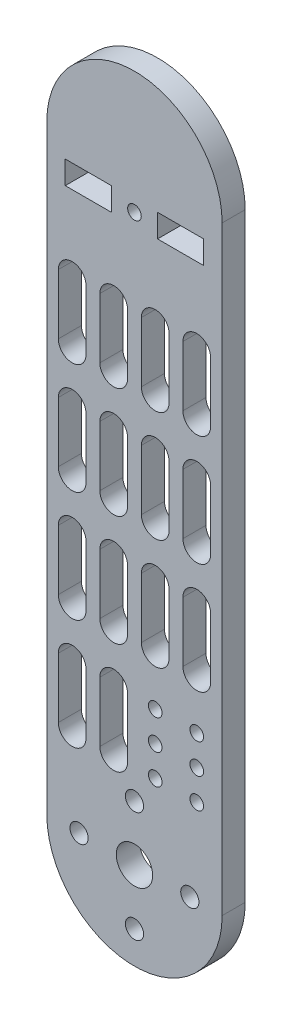
from build123d import *

# Parameters (mm, degrees)
SKETCH1_R           = 3.95
SKETCH1_R_2         = 1.975
SKETCH1_R_3         = 1.475
SKETCH1_W           = 10
SKETCH1_H           = 5
BOSS_EXTRUDE1_DEPTH = 5


with BuildPart() as part:
    # Sketch1 → Boss-Extrude1 (new body)
    with BuildSketch(Plane.XY):
        with BuildLine():
            Line((-19, 0), (-19, 130))
            ThreePointArc((-19, 130), (0, 149), (19, 130))
            Line((19, 130), (19, 0))
            ThreePointArc((19, 0), (0, -19), (-19, 0))
        make_face()
        Circle(SKETCH1_R, mode=Mode.SUBTRACT)
        with Locations((0, 12)):
            Circle(SKETCH1_R_2, mode=Mode.SUBTRACT)
        with Locations((12, 0)):
            Circle(SKETCH1_R_2, mode=Mode.SUBTRACT)
        with Locations((0, -12)):
            Circle(SKETCH1_R_2, mode=Mode.SUBTRACT)
        with Locations((-12, 0)):
            Circle(SKETCH1_R_2, mode=Mode.SUBTRACT)
        with Locations((13.5, 25)):
            Circle(SKETCH1_R_3, mode=Mode.SUBTRACT)
        with Locations((4.5, 25)):
            Circle(SKETCH1_R_3, mode=Mode.SUBTRACT)
        with Locations((13.5, 31.5)):
            Circle(SKETCH1_R_3, mode=Mode.SUBTRACT)
        with Locations((4.5, 31.5)):
            Circle(SKETCH1_R_3, mode=Mode.SUBTRACT)
        with Locations((13.5, 18.5)):
            Circle(SKETCH1_R_3, mode=Mode.SUBTRACT)
        with Locations((4.5, 18.5)):
            Circle(SKETCH1_R_3, mode=Mode.SUBTRACT)
        with Locations((0, 122.5)):
            Circle(SKETCH1_R_3, mode=Mode.SUBTRACT)
        with BuildLine():
            Line((7.5, 103.5), (7.5, 90.5))
            ThreePointArc((7.5, 90.5), (4.5, 87.5), (1.5, 90.5))
            Line((1.5, 90.5), (1.5, 103.5))
            ThreePointArc((1.5, 103.5), (4.5, 106.5), (7.5, 103.5))
        make_face(mode=Mode.SUBTRACT)
        with BuildLine():
            Line((-7.5, 103.5), (-7.5, 90.5))
            ThreePointArc((-7.5, 90.5), (-4.5, 87.5), (-1.5, 90.5))
            Line((-1.5, 90.5), (-1.5, 103.5))
            ThreePointArc((-1.5, 103.5), (-4.5, 106.5), (-7.5, 103.5))
        make_face(mode=Mode.SUBTRACT)
        with BuildLine():
            Line((16.5, 103.5), (16.5, 90.5))
            ThreePointArc((16.5, 90.5), (13.5, 87.5), (10.5, 90.5))
            Line((10.5, 90.5), (10.5, 103.5))
            ThreePointArc((10.5, 103.5), (13.5, 106.5), (16.5, 103.5))
        make_face(mode=Mode.SUBTRACT)
        with BuildLine():
            Line((-16.5, 103.5), (-16.5, 90.5))
            ThreePointArc((-16.5, 90.5), (-13.5, 87.5), (-10.5, 90.5))
            Line((-10.5, 90.5), (-10.5, 103.5))
            ThreePointArc((-10.5, 103.5), (-13.5, 106.5), (-16.5, 103.5))
        make_face(mode=Mode.SUBTRACT)
        with BuildLine():
            Line((7.5, 79.5), (7.5, 66.5))
            ThreePointArc((7.5, 66.5), (4.5, 63.5), (1.5, 66.5))
            Line((1.5, 66.5), (1.5, 79.5))
            ThreePointArc((1.5, 79.5), (4.5, 82.5), (7.5, 79.5))
        make_face(mode=Mode.SUBTRACT)
        with BuildLine():
            Line((-7.5, 79.5), (-7.5, 66.5))
            ThreePointArc((-7.5, 66.5), (-4.5, 63.5), (-1.5, 66.5))
            Line((-1.5, 66.5), (-1.5, 79.5))
            ThreePointArc((-1.5, 79.5), (-4.5, 82.5), (-7.5, 79.5))
        make_face(mode=Mode.SUBTRACT)
        with BuildLine():
            Line((16.5, 79.5), (16.5, 66.5))
            ThreePointArc((16.5, 66.5), (13.5, 63.5), (10.5, 66.5))
            Line((10.5, 66.5), (10.5, 79.5))
            ThreePointArc((10.5, 79.5), (13.5, 82.5), (16.5, 79.5))
        make_face(mode=Mode.SUBTRACT)
        with BuildLine():
            Line((-16.5, 79.5), (-16.5, 66.5))
            ThreePointArc((-16.5, 66.5), (-13.5, 63.5), (-10.5, 66.5))
            Line((-10.5, 66.5), (-10.5, 79.5))
            ThreePointArc((-10.5, 79.5), (-13.5, 82.5), (-16.5, 79.5))
        make_face(mode=Mode.SUBTRACT)
        with BuildLine():
            Line((7.5, 55.5), (7.5, 42.5))
            ThreePointArc((7.5, 42.5), (4.5, 39.5), (1.5, 42.5))
            Line((1.5, 42.5), (1.5, 55.5))
            ThreePointArc((1.5, 55.5), (4.5, 58.5), (7.5, 55.5))
        make_face(mode=Mode.SUBTRACT)
        with BuildLine():
            Line((-7.5, 55.5), (-7.5, 42.5))
            ThreePointArc((-7.5, 42.5), (-4.5, 39.5), (-1.5, 42.5))
            Line((-1.5, 42.5), (-1.5, 55.5))
            ThreePointArc((-1.5, 55.5), (-4.5, 58.5), (-7.5, 55.5))
        make_face(mode=Mode.SUBTRACT)
        with BuildLine():
            Line((16.5, 55.5), (16.5, 42.5))
            ThreePointArc((16.5, 42.5), (13.5, 39.5), (10.5, 42.5))
            Line((10.5, 42.5), (10.5, 55.5))
            ThreePointArc((10.5, 55.5), (13.5, 58.5), (16.5, 55.5))
        make_face(mode=Mode.SUBTRACT)
        with BuildLine():
            Line((-16.5, 55.5), (-16.5, 42.5))
            ThreePointArc((-16.5, 42.5), (-13.5, 39.5), (-10.5, 42.5))
            Line((-10.5, 42.5), (-10.5, 55.5))
            ThreePointArc((-10.5, 55.5), (-13.5, 58.5), (-16.5, 55.5))
        make_face(mode=Mode.SUBTRACT)
        with BuildLine():
            Line((-7.5, 31.5), (-7.5, 18.5))
            ThreePointArc((-7.5, 18.5), (-4.5, 15.5), (-1.5, 18.5))
            Line((-1.5, 18.5), (-1.5, 31.5))
            ThreePointArc((-1.5, 31.5), (-4.5, 34.5), (-7.5, 31.5))
        make_face(mode=Mode.SUBTRACT)
        with BuildLine():
            Line((-16.5, 31.5), (-16.5, 18.5))
            ThreePointArc((-16.5, 18.5), (-13.5, 15.5), (-10.5, 18.5))
            Line((-10.5, 18.5), (-10.5, 31.5))
            ThreePointArc((-10.5, 31.5), (-13.5, 34.5), (-16.5, 31.5))
        make_face(mode=Mode.SUBTRACT)
        with Locations((10, 122.5)):
            Rectangle(SKETCH1_W, SKETCH1_H, mode=Mode.SUBTRACT)
        with Locations((-10, 122.5)):
            Rectangle(SKETCH1_W, SKETCH1_H, mode=Mode.SUBTRACT)
    extrude(amount=BOSS_EXTRUDE1_DEPTH)


solid = part.part
